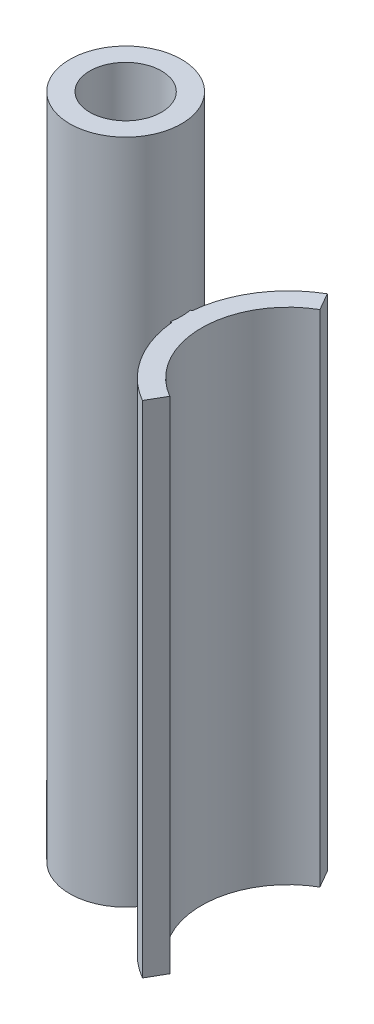
from build123d import *

# Parameters (mm, degrees)
SKETCH1_R           = 8.375
SKETCH1_R_2         = 5.375
BOSS_EXTRUDE1_DEPTH = 100
BOSS_EXTRUDE2_DEPTH = 75


with BuildPart() as part:
    # Sketch1 → Boss-Extrude1 (new body)
    with BuildSketch(Plane(origin=(0, 0, 0), x_dir=(1, 0, 0), z_dir=(0, 1, 0))):
        Circle(SKETCH1_R)
        Circle(SKETCH1_R_2, mode=Mode.SUBTRACT)
    extrude(amount=BOSS_EXTRUDE1_DEPTH)

    # Sketch2 → Boss-Extrude2 (add)
    with BuildSketch(Plane(origin=(0, 0, 0), x_dir=(1, 0, 0), z_dir=(0, 1, 0))):
        with BuildLine():
            Line((8.445467678, 1.5), (8.239576749, 1.5))
            ThreePointArc((8.239576749, 1.5), (8.375, 0), (8.239576749, -1.5))
            Line((8.239576749, -1.5), (8.445467678, -1.5))
            ThreePointArc((8.445467678, -1.5), (10.909272228, -8.64142208), (16.375, -13.856406461))
            Line((16.375, -13.856406461), (17.875, -11.258330249))
            ThreePointArc((17.875, -11.258330249), (11.375, 0), (17.875, 11.258330249))
            Line((17.875, 11.258330249), (16.375, 13.856406461))
            ThreePointArc((16.375, 13.856406461), (10.909272228, 8.64142208), (8.445467678, 1.5))
        make_face()
    extrude(amount=BOSS_EXTRUDE2_DEPTH)


solid = part.part
